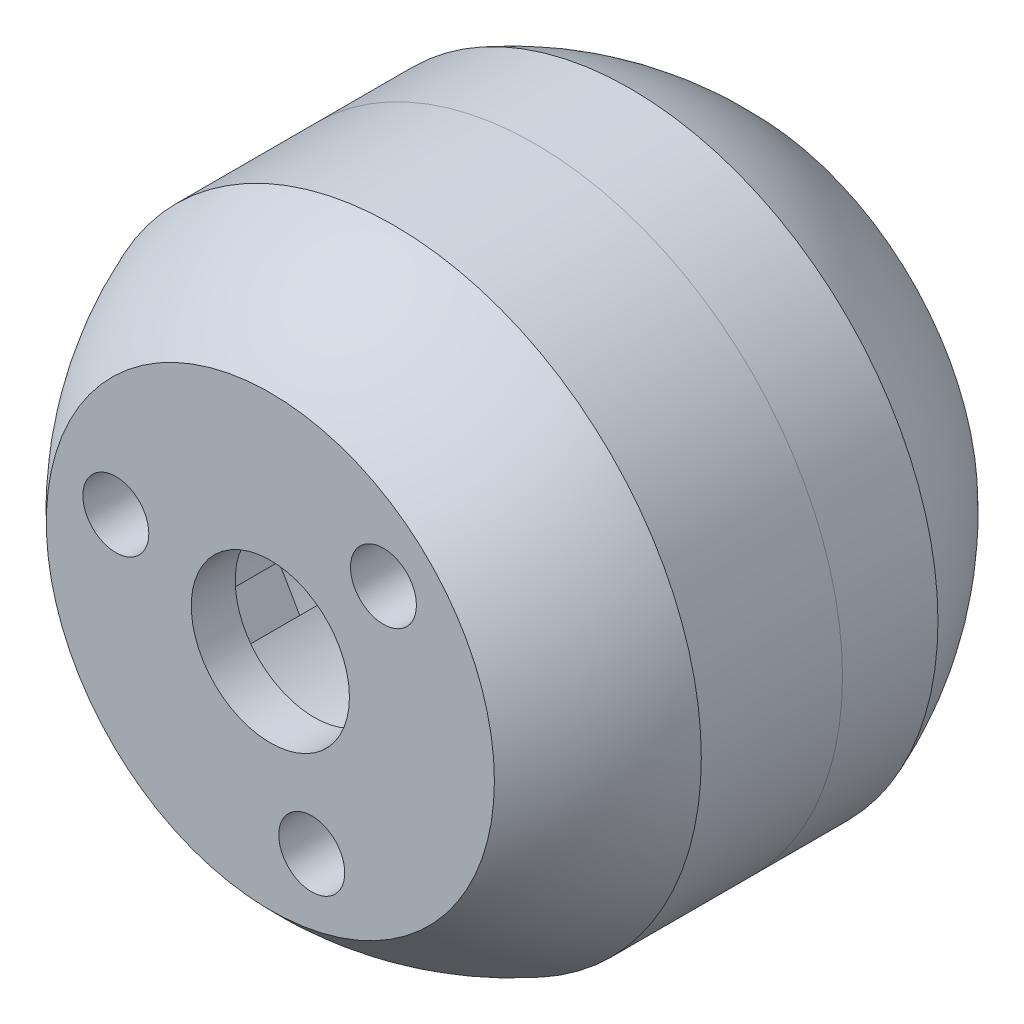
from build123d import *

# Parameters (mm, degrees)
SKETCH2_R          = 41.4782
CUT_EXTRUDE1_DEPTH = 3.302
SKETCH3_R          = 4.7625
CUT_EXTRUDE2_DEPTH = 35.925
SKETCH4_R          = 4.7625
CUT_EXTRUDE3_DEPTH = 35.925
SKETCH6_W          = 18.415
SKETCH6_H          = 18.415
CUT_EXTRUDE5_DEPTH = 28.8925
CIRPATTERN1_COUNT  = 3
CUT_EXTRUDE4_START = 28.575
SKETCH5_R          = 18.034
CUT_EXTRUDE4_DEPTH = 64.5
SKETCH7_R          = 11.43
CUT_EXTRUDE6_DEPTH = 70.85


with BuildPart() as part:
    # Sketch1 → Revolve2 (revolve)
    with BuildSketch(Plane(origin=(0, 0, 0), x_dir=(0, 0, -1), z_dir=(1, 0, 0))):
        with BuildLine():
            Line((-34.925, 0), (-34.925, 32.378773911))
            ThreePointArc((-34.925, 32.378773911), (-26.702511319, 39.43496563), (-17.097898263, 44.45))
            Line((-17.097898263, 44.45), (17.097898263, 44.45))
            ThreePointArc((17.097898263, 44.45), (26.702511319, 39.43496563), (34.925, 32.378773911))
            Line((34.925, 32.378773911), (34.925, 0))
            Line((34.925, 0), (0, 0))
            Line((0, 0), (-34.925, 0))
        make_face()
    revolve(axis=Axis((0, 0, 34.925), (0, 0, -1)))

    # Sketch2 → Cut-Extrude1 (cut, symmetric)
    with BuildSketch(Plane.XY):
        Circle(SKETCH2_R)
    extrude(amount=CUT_EXTRUDE1_DEPTH, both=True, mode=Mode.SUBTRACT)

    # Sketch3 → Cut-Extrude2 (cut, through all)
    with BuildSketch(Plane.XY):
        with Locations((-22.326409549, 5.982343408)):
            Circle(SKETCH3_R)
    cut_extrude2 = extrude(amount=CUT_EXTRUDE2_DEPTH, mode=Mode.SUBTRACT)

    # Sketch4 → Cut-Extrude3 (cut, through all)
    with BuildSketch(Plane.XY):
        with Locations((-16.34406614, 16.34406614)):
            Circle(SKETCH4_R)
    cut_extrude3 = extrude(amount=-CUT_EXTRUDE3_DEPTH, mode=Mode.SUBTRACT)

    # Sketch6 → Cut-Extrude5 (cut, symmetric)
    with BuildSketch(Plane.XY):
        with Locations((0, 26.9875)):
            Rectangle(SKETCH6_W, SKETCH6_H)
    cut_extrude5 = extrude(amount=CUT_EXTRUDE5_DEPTH, both=True, mode=Mode.SUBTRACT)

    # CirPattern1: Cut-Extrude2, Cut-Extrude3, Cut-Extrude5 ×3 about axis
    cirpattern1_axis = Axis((0, 0, 0), (0, 0, 1))
    for i in range(1, CIRPATTERN1_COUNT):
        add(cut_extrude2.rotate(cirpattern1_axis, i * 360 / CIRPATTERN1_COUNT), mode=Mode.SUBTRACT)
        add(cut_extrude3.rotate(cirpattern1_axis, i * 360 / CIRPATTERN1_COUNT), mode=Mode.SUBTRACT)
        add(cut_extrude5.rotate(cirpattern1_axis, i * 360 / CIRPATTERN1_COUNT), mode=Mode.SUBTRACT)

    # Sketch5 → Cut-Extrude4 (cut, through all)
    with BuildSketch(Plane.XY.offset(CUT_EXTRUDE4_START)):
        Circle(SKETCH5_R)
    extrude(amount=-CUT_EXTRUDE4_DEPTH, mode=Mode.SUBTRACT)

    # Sketch7 → Cut-Extrude6 (cut, through all)
    with BuildSketch(Plane.XY.offset(34.925)):
        Circle(SKETCH7_R)
    extrude(amount=-CUT_EXTRUDE6_DEPTH, mode=Mode.SUBTRACT)


with BuildPart() as body_2:
    # Split1: the piece on the far side of the plane
    add(part.part)
    split(bisect_by=Plane.XY.offset(-3.302), keep=Keep.BOTTOM)


with BuildPart() as part_1:
    add(part.part)

    # Split1
    split(bisect_by=Plane.XY.offset(-3.302), keep=Keep.TOP)


solid = Compound([body_2.part, part_1.part])
